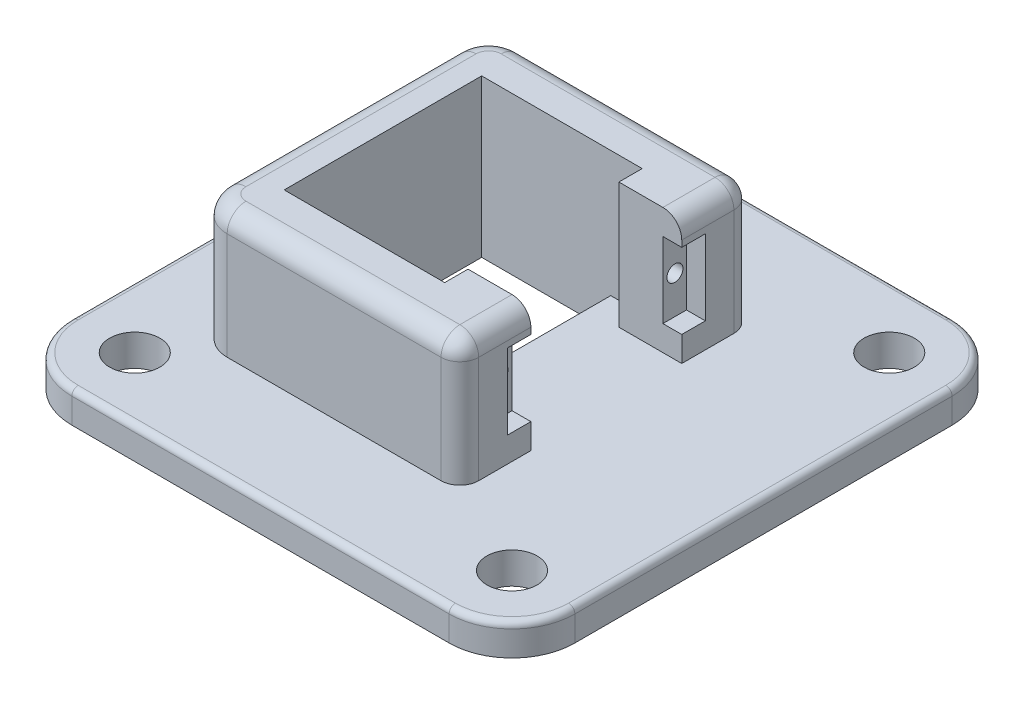
from build123d import *

# Parameters (mm, degrees)
SKETCH_1_R          = 4
EXTRUDE_1_DEPTH     = 5
SKETCH_2_W          = 20.529114817
SKETCH_2_H          = 31.412366712
CUT_EXTRUDE_1_DEPTH = 5
EXTRUDE_2_DEPTH     = 20
SKETCH_4_W          = 7.585483435
SKETCH_4_H          = 20
EXTRUDE_3_DEPTH     = 10
SKETCH_5_W          = 7.585483435
SKETCH_5_H          = 20
SKETCH_5_W_2        = 3.706183356
EXTRUDE_4_DEPTH     = 5
SKETCH_6_W          = 3.75
SKETCH_6_H          = 12
CUT_EXTRUDE_2_DEPTH = 3
CUT_EXTRUDE_3_REACH = 54
SKETCH_7_R          = 1.275
FILLET_1_R          = 3
FILLET_2_R          = 1


with BuildPart() as part:
    # 草图1 → 凸台-拉伸1 (new body)
    with BuildSketch(Plane(origin=(0, 0, 0), x_dir=(1, 0, 0), z_dir=(0, 1, 0))):
        with BuildLine():
            Line((30, 40), (-30, 40))
            ThreePointArc((-30, 40), (-37.071067812, 37.071067812), (-40, 30))
            Line((-40, 30), (-40, -30))
            ThreePointArc((-40, -30), (-37.071067812, -37.071067812), (-30, -40))
            Line((-30, -40), (30, -40))
            ThreePointArc((30, -40), (37.071067812, -37.071067812), (40, -30))
            Line((40, -30), (40, 30))
            ThreePointArc((40, 30), (37.071067812, 37.071067812), (30, 40))
        make_face()
        with Locations((-30, 30)):
            Circle(SKETCH_1_R, mode=Mode.SUBTRACT)
        with Locations((-30, -30)):
            Circle(SKETCH_1_R, mode=Mode.SUBTRACT)
        with Locations((30, -30)):
            Circle(SKETCH_1_R, mode=Mode.SUBTRACT)
        with Locations((30, 30)):
            Circle(SKETCH_1_R, mode=Mode.SUBTRACT)
    extrude(amount=EXTRUDE_1_DEPTH)

    # 草图2 → 切除-拉伸1 (cut)
    with BuildSketch(Plane(origin=(0, 5, 0), x_dir=(1, 0, 0), z_dir=(0, 1, 0))):
        with Locations((-10.264557408, 0)):
            Rectangle(SKETCH_2_W, SKETCH_2_H)
    extrude(amount=-CUT_EXTRUDE_1_DEPTH, mode=Mode.SUBTRACT)

    # 草图3 → 凸台-拉伸2 (add)
    with BuildSketch(Plane(origin=(0, 5, 0), x_dir=(1, 0, 0), z_dir=(0, 1, 0))):
        with BuildLine():
            Line((0, -15.706183356), (-20.529114817, -15.706183356))
            Line((-20.529114817, -15.706183356), (-20.529114817, 15.706183356))
            Line((-20.529114817, 15.706183356), (0, 15.706183356))
            Line((0, 15.706183356), (0, 23.291666791))
            Line((0, 23.291666791), (-22.012764878, 23.291666791))
            ThreePointArc((-22.012764878, 23.291666791), (-25.548298784, 21.827200697), (-27.012764878, 18.291666791))
            Line((-27.012764878, 18.291666791), (-27.012764878, -18.291666791))
            ThreePointArc((-27.012764878, -18.291666791), (-25.548298784, -21.827200697), (-22.012764878, -23.291666791))
            Line((-22.012764878, -23.291666791), (0, -23.291666791))
            Line((0, -23.291666791), (0, -15.706183356))
        make_face()
    extrude(amount=EXTRUDE_2_DEPTH)

    # 草图4 → 凸台-拉伸3 (add)
    with BuildSketch(Plane(origin=(0, 0, 0), x_dir=(0, 0, -1), z_dir=(1, 0, 0))):
        with Locations((19.498925074, 15)):
            Rectangle(SKETCH_4_W, SKETCH_4_H)
        with Locations((-19.498925074, 15)):
            Rectangle(SKETCH_4_W, SKETCH_4_H)
    extrude(amount=EXTRUDE_3_DEPTH)

    # 草图5 → 凸台-拉伸4 (add, symmetric)
    with BuildSketch(Plane(origin=(10, 0, 0), x_dir=(0, 0, -1), z_dir=(1, 0, 0))):
        with Locations((-19.498925074, 15)):
            Rectangle(SKETCH_5_W, SKETCH_5_H)
        with Locations((-13.853091678, 15)):
            Rectangle(SKETCH_5_W_2, SKETCH_5_H)
        with Locations((13.853091678, 15)):
            Rectangle(SKETCH_5_W_2, SKETCH_5_H)
        with Locations((19.498925074, 15)):
            Rectangle(SKETCH_5_W, SKETCH_5_H)
    extrude(amount=EXTRUDE_4_DEPTH, both=True)

    # 草图6 → 切除-拉伸2 (cut)
    with BuildSketch(Plane(origin=(15, 0, 0), x_dir=(0, 0, -1), z_dir=(1, 0, 0))):
        with Locations((-13.875, 15)):
            Rectangle(SKETCH_6_W, SKETCH_6_H)
        with Locations((13.875, 15)):
            Rectangle(SKETCH_6_W, SKETCH_6_H)
    extrude(amount=-CUT_EXTRUDE_2_DEPTH, mode=Mode.SUBTRACT)

    # 草图7 → 切除-拉伸3 (cut, up to next)
    with BuildSketch(Plane(origin=(12, 0, 0), x_dir=(0, 0, -1), z_dir=(1, 0, 0)), mode=Mode.PRIVATE) as cut_extrude_3_sk1:
        with Locations((-13.91, 15)):
            Circle(SKETCH_7_R)
    cut_extrude_3_tool1 = extrude(cut_extrude_3_sk1.sketch, amount=-CUT_EXTRUDE_3_REACH, mode=Mode.PRIVATE) & part.part
    add(cut_extrude_3_tool1.solids().sort_by_distance((12, 15, 13.91))[0], mode=Mode.SUBTRACT)
    # 草图7 → 切除-拉伸3 (cut, up to next)
    with BuildSketch(Plane(origin=(12, 0, 0), x_dir=(0, 0, -1), z_dir=(1, 0, 0)), mode=Mode.PRIVATE) as cut_extrude_3_sk2:
        with Locations((13.91, 15)):
            Circle(SKETCH_7_R)
    cut_extrude_3_tool2 = extrude(cut_extrude_3_sk2.sketch, amount=-CUT_EXTRUDE_3_REACH, mode=Mode.PRIVATE) & part.part
    add(cut_extrude_3_tool2.solids().sort_by_distance((12, 15, -13.91))[0], mode=Mode.SUBTRACT)

    # 圆角1
    fillet_1_edges = [part.edges().sort_by_distance(p)[0] for p in [
        (15, 25, 17.645833395),
        (15, 15, 23.291666791),
        (15, 25, -17.645833395),
        (15, 15, -23.291666791),
        (-27.012764878, 25, 0),
        (-25.548298784, 25, 21.827200697),
        (-3.506382439, 25, 23.291666791),
        (-3.506382439, 25, -23.291666791),
        (-25.548298784, 25, -21.827200697),
    ]]
    fillet(fillet_1_edges, radius=FILLET_1_R)

    # 圆角2
    fillet_2_edges = [part.edges().sort_by_distance(p)[0] for p in [
        (37.071067812, 5, -37.071067812),
        (0, 5, -40),
        (-37.071067812, 5, -37.071067812),
        (-40, 5, 0),
        (-37.071067812, 5, 37.071067812),
        (0, 5, 40),
        (37.071067812, 5, 37.071067812),
        (40, 5, 0),
    ]]
    fillet(fillet_2_edges, radius=FILLET_2_R)


solid = part.part
